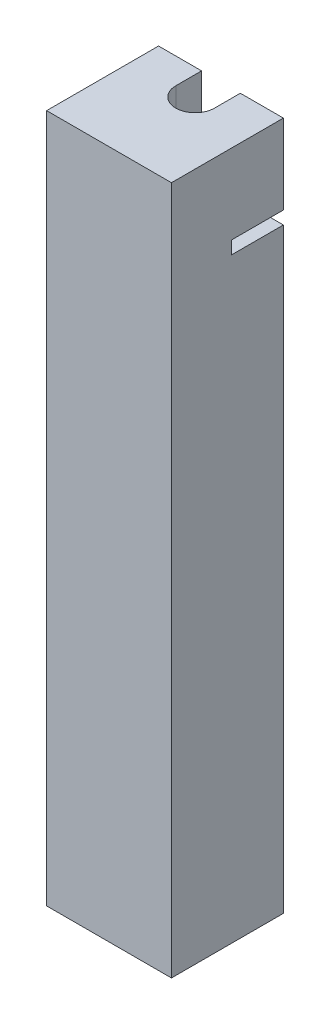
from build123d import *
from build123d.topology import SkipClean

# Parameters (mm, degrees)
BOSS_EXTRUDE1_DEPTH = 40
SKETCH2_W           = 14.5
SKETCH2_H           = 1.5
CUT_EXTRUDE1_DEPTH  = 6
BOSS_EXTRUDE2_REACH = 44.68
SKETCH2_3_W         = 14.5
SKETCH2_3_H         = 9.25
BOSS_EXTRUDE3_START = 3
BOSS_EXTRUDE3_DEPTH = 3


with BuildPart() as part:
    # Sketch1 → Boss-Extrude1 (new, symmetric)
    with BuildSketch(Plane(origin=(0, 0, 0), x_dir=(1, 0, 0), z_dir=(0, 1, 0))):
        with BuildLine():
            Line((-7.25, 3), (-2.25, 3))
            Line((-2.25, 3), (-2.25, 0))
            ThreePointArc((-2.25, 0), (0, -2.25), (2.25, 0))
            Line((2.25, 0), (2.25, 3))
            Line((2.25, 3), (7.25, 3))
            Line((7.25, 3), (7.25, -10))
            Line((7.25, -10), (-7.25, -10))
            Line((-7.25, -10), (-7.25, 3))
        make_face()
    extrude(amount=BOSS_EXTRUDE1_DEPTH, both=True)

    # Sketch2 → Cut-Extrude1 (cut)
    with BuildSketch(Plane(origin=(0, 0, -3), x_dir=(-1, 0, 0), z_dir=(0, 0, -1))):
        with Locations((0, 30)):
            Rectangle(SKETCH2_W, SKETCH2_H)
    extrude(amount=-CUT_EXTRUDE1_DEPTH, mode=Mode.SUBTRACT)

    # Sketch2_3 → Boss-Extrude2 (add, up to next)
    with BuildSketch(Plane(origin=(0, 0, -3), x_dir=(-1, 0, 0), z_dir=(0, 0, -1)), mode=Mode.PRIVATE) as boss_extrude2_sk1:
        with Locations((0, -35.375)):
            Rectangle(SKETCH2_3_W, SKETCH2_3_H)
    boss_extrude2_tool1 = extrude(boss_extrude2_sk1.sketch, amount=-BOSS_EXTRUDE2_REACH, mode=Mode.PRIVATE) - part.part
    add(boss_extrude2_tool1.solids().sort_by_distance((0, -35.375, -3))[0])

    # Sketch3 → Boss-Extrude3 (add)
    with SkipClean():  # the faces are left unmerged after this step: merging them gives an invalid solid
        with BuildSketch(Plane(origin=(0, -30.75, 0), x_dir=(1, 0, 0), z_dir=(0, 1, 0)).offset(BOSS_EXTRUDE3_START)):
            with BuildLine():
                Line((2.25, 0), (2.25, 3))
                Line((2.25, 3), (-2.25, 3))
                Line((-2.25, 3), (-2.25, 0))
                ThreePointArc((-2.25, 0), (0, 2.25), (2.25, 0))
            make_face()
        extrude(amount=-BOSS_EXTRUDE3_DEPTH)


solid = part.part
